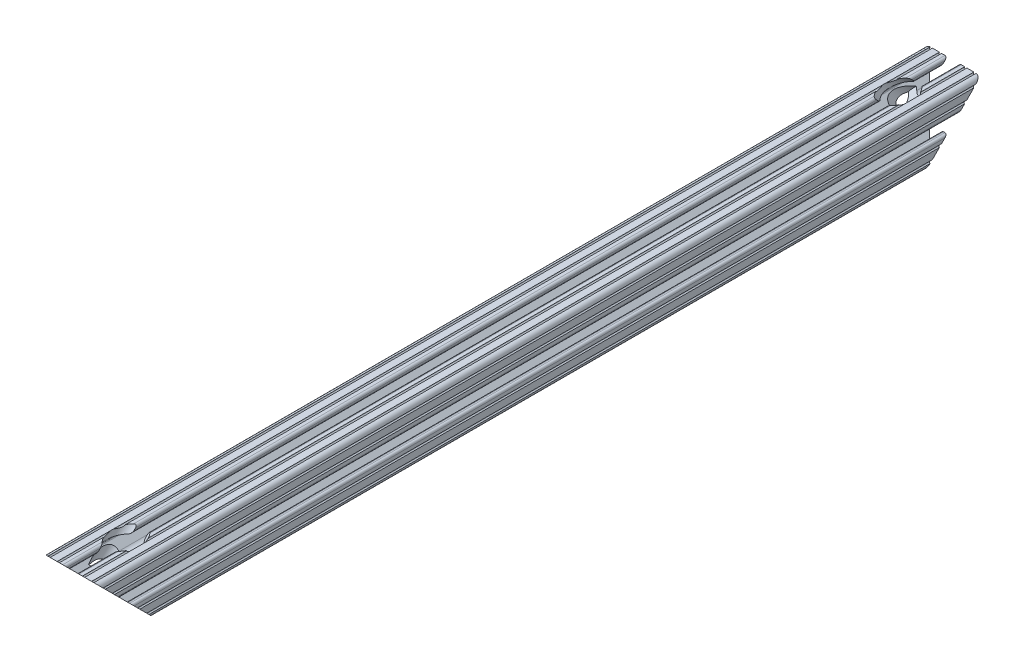
from build123d import *

# Parameters (mm, degrees)
SKETCH1_R               = 3.3274
BOSS_EXTRUDE1_DEPTH     = 304.8
CUT_EXTRUDE1_DEPTH      = 306.988323561
CUT_EXTRUDE1_DEPTH_BACK = 306.988323561


with BuildPart() as part:
    # Sketch1 → Boss-Extrude1 (new, symmetric)
    with BuildSketch(Plane.XY):
        with BuildLine():
            Line((-10.287, 13.552357131), (-10.287, 14.0843))
            ThreePointArc((-10.287, 14.0843), (-10.022898185, 14.721898185), (-9.3853, 14.986))
            Line((-9.3853, 14.986), (-5.617617549, 14.986))
            ThreePointArc((-5.617617549, 14.986), (-4.519044045, 15.441044045), (-4.064, 16.539617549))
            Line((-4.064, 16.539617549), (-4.064, 17.496382451))
            ThreePointArc((-4.064, 17.496382451), (-4.519044045, 18.594955955), (-5.617617549, 19.05))
            Line((-5.617617549, 19.05), (-7.974178704, 19.05))
            ThreePointArc((-7.974178704, 19.05), (-8.736178704, 18.288), (-9.498178704, 19.05))
            Line((-9.498178704, 19.05), (-14.327719207, 19.05))
            ThreePointArc((-14.327719207, 19.05), (-15.087603123, 18.231251131), (-15.847487039, 19.05))
            ThreePointArc((-15.847487039, 19.05), (-18.120176289, 18.120192083), (-19.05, 15.847509295))
            ThreePointArc((-19.05, 15.847509295), (-18.231250992, 15.08762539), (-19.05, 14.327741484))
            Line((-19.05, 14.327741484), (-19.05, 9.496091471))
            ThreePointArc((-19.05, 9.496091471), (-18.231250992, 8.736207565), (-19.05, 7.97632366))
            Line((-19.05, 7.97632366), (-19.05, 5.617617549))
            ThreePointArc((-19.05, 5.617617549), (-18.594955955, 4.519044045), (-17.496382451, 4.064))
            Line((-17.496382451, 4.064), (-16.539617549, 4.064))
            ThreePointArc((-16.539617549, 4.064), (-15.441044045, 4.519044045), (-14.986, 5.617617549))
            Line((-14.986, 5.617617549), (-14.986, 9.385342516))
            ThreePointArc((-14.986, 9.385342516), (-14.721898185, 10.022940701), (-14.0843, 10.287042516))
            Line((-14.0843, 10.287042516), (-13.516042086, 10.287042516))
            ThreePointArc((-13.516042086, 10.287042516), (-13.170975923, 10.218404478), (-12.878443117, 10.022939917))
            Line((-12.878443117, 10.022939917), (-8.14758008, 5.292065243))
            ThreePointArc((-8.14758008, 5.292065243), (-7.117955879, 3.751120653), (-6.7564, 1.933453584))
            Line((-6.7564, 1.933453584), (-6.7564, -1.933453584))
            ThreePointArc((-6.7564, -1.933453584), (-7.117955879, -3.751120653), (-8.14758008, -5.292065243))
            Line((-8.14758008, -5.292065243), (-12.878443117, -10.022939917))
            ThreePointArc((-12.878443117, -10.022939917), (-13.170975923, -10.218404478), (-13.516042086, -10.287042516))
            Line((-13.516042086, -10.287042516), (-14.0843, -10.287042516))
            ThreePointArc((-14.0843, -10.287042516), (-14.721898185, -10.022940701), (-14.986, -9.385342516))
            Line((-14.986, -9.385342516), (-14.986, -5.617617549))
            ThreePointArc((-14.986, -5.617617549), (-15.441044045, -4.519044045), (-16.539617549, -4.064))
            Line((-16.539617549, -4.064), (-17.496382451, -4.064))
            ThreePointArc((-17.496382451, -4.064), (-18.594955955, -4.519044045), (-19.05, -5.617617549))
            Line((-19.05, -5.617617549), (-19.05, -7.976318491))
            ThreePointArc((-19.05, -7.976318491), (-18.231250992, -8.736202396), (-19.05, -9.496086302))
            Line((-19.05, -9.496086302), (-19.05, -14.32774291))
            ThreePointArc((-19.05, -14.32774291), (-18.231250992, -15.087626816), (-19.05, -15.847510721))
            ThreePointArc((-19.05, -15.847510721), (-18.120175716, -18.120192644), (-15.847486868, -19.05))
            ThreePointArc((-15.847486868, -19.05), (-15.087602952, -18.231251131), (-14.327719036, -19.05))
            Line((-14.327719036, -19.05), (-9.496062448, -19.05))
            ThreePointArc((-9.496062448, -19.05), (-8.736178532, -18.231251131), (-7.976294616, -19.05))
            Line((-7.976294616, -19.05), (-5.617617549, -19.05))
            ThreePointArc((-5.617617549, -19.05), (-4.519044045, -18.594955955), (-4.064, -17.496382451))
            Line((-4.064, -17.496382451), (-4.064, -16.539617549))
            ThreePointArc((-4.064, -16.539617549), (-4.519044045, -15.441044045), (-5.617617549, -14.986))
            Line((-5.617617549, -14.986), (-9.3853, -14.986))
            ThreePointArc((-9.3853, -14.986), (-10.022898185, -14.721898185), (-10.287, -14.0843))
            Line((-10.287, -14.0843), (-10.287, -13.552357131))
            ThreePointArc((-10.287, -13.552357131), (-10.218362387, -13.207291992), (-10.022898969, -12.91475973))
            Line((-10.022898969, -12.91475973), (-5.252158105, -8.144007132))
            ThreePointArc((-5.252158105, -8.144007132), (-3.715177372, -7.117027388), (-1.902183975, -6.7564))
            Line((-1.902183975, -6.7564), (1.902183975, -6.7564))
            ThreePointArc((1.902183975, -6.7564), (3.715177372, -7.117027388), (5.252158105, -8.144007132))
            Line((5.252158105, -8.144007132), (10.022898969, -12.91475973))
            ThreePointArc((10.022898969, -12.91475973), (10.218362387, -13.207291992), (10.287, -13.552357131))
            Line((10.287, -13.552357131), (10.287, -14.0843))
            ThreePointArc((10.287, -14.0843), (10.022898185, -14.721898185), (9.3853, -14.986))
            Line((9.3853, -14.986), (5.617617549, -14.986))
            ThreePointArc((5.617617549, -14.986), (4.519044045, -15.441044045), (4.064, -16.539617549))
            Line((4.064, -16.539617549), (4.064, -17.496382451))
            ThreePointArc((4.064, -17.496382451), (4.519044045, -18.594955955), (5.617617549, -19.05))
            Line((5.617617549, -19.05), (7.976294616, -19.05))
            ThreePointArc((7.976294616, -19.05), (8.736178532, -18.231251131), (9.496062448, -19.05))
            Line((9.496062448, -19.05), (14.327719036, -19.05))
            ThreePointArc((14.327719036, -19.05), (15.087602952, -18.231251131), (15.847486868, -19.05))
            ThreePointArc((15.847486868, -19.05), (18.120175716, -18.120192644), (19.05, -15.847510721))
            ThreePointArc((19.05, -15.847510721), (18.231250992, -15.087626816), (19.05, -14.32774291))
            Line((19.05, -14.32774291), (19.05, -9.496086302))
            ThreePointArc((19.05, -9.496086302), (18.231250992, -8.736202396), (19.05, -7.976318491))
            Line((19.05, -7.976318491), (19.05, -5.617617549))
            ThreePointArc((19.05, -5.617617549), (18.594955955, -4.519044045), (17.496382451, -4.064))
            Line((17.496382451, -4.064), (16.539617549, -4.064))
            ThreePointArc((16.539617549, -4.064), (15.441044045, -4.519044045), (14.986, -5.617617549))
            Line((14.986, -5.617617549), (14.986, -9.385342516))
            ThreePointArc((14.986, -9.385342516), (14.721898185, -10.022940701), (14.0843, -10.287042516))
            Line((14.0843, -10.287042516), (13.516042086, -10.287042516))
            ThreePointArc((13.516042086, -10.287042516), (13.170975923, -10.218404478), (12.878443117, -10.022939917))
            Line((12.878443117, -10.022939917), (8.14758008, -5.292065243))
            ThreePointArc((8.14758008, -5.292065243), (7.117955879, -3.751120653), (6.7564, -1.933453584))
            Line((6.7564, -1.933453584), (6.7564, 1.933453584))
            ThreePointArc((6.7564, 1.933453584), (7.117955879, 3.751120653), (8.14758008, 5.292065243))
            Line((8.14758008, 5.292065243), (12.878443117, 10.022939917))
            ThreePointArc((12.878443117, 10.022939917), (13.170975923, 10.218404478), (13.516042086, 10.287042516))
            Line((13.516042086, 10.287042516), (14.0843, 10.287042516))
            ThreePointArc((14.0843, 10.287042516), (14.721898185, 10.022940701), (14.986, 9.385342516))
            Line((14.986, 9.385342516), (14.986, 5.617617549))
            ThreePointArc((14.986, 5.617617549), (15.441044045, 4.519044045), (16.539617549, 4.064))
            Line((16.539617549, 4.064), (17.496382451, 4.064))
            ThreePointArc((17.496382451, 4.064), (18.594955955, 4.519044045), (19.05, 5.617617549))
            Line((19.05, 5.617617549), (19.05, 7.97632366))
            ThreePointArc((19.05, 7.97632366), (18.231250992, 8.736207565), (19.05, 9.496091471))
            Line((19.05, 9.496091471), (19.05, 14.327741484))
            ThreePointArc((19.05, 14.327741484), (18.231250992, 15.08762539), (19.05, 15.847509295))
            ThreePointArc((19.05, 15.847509295), (18.120176289, 18.120192083), (15.847487039, 19.05))
            ThreePointArc((15.847487039, 19.05), (15.087603123, 18.231251131), (14.327719207, 19.05))
            Line((14.327719207, 19.05), (9.498178704, 19.05))
            ThreePointArc((9.498178704, 19.05), (8.736178704, 18.288), (7.974178704, 19.05))
            Line((7.974178704, 19.05), (5.617617549, 19.05))
            ThreePointArc((5.617617549, 19.05), (4.519044045, 18.594955955), (4.064, 17.496382451))
            Line((4.064, 17.496382451), (4.064, 16.539617549))
            ThreePointArc((4.064, 16.539617549), (4.519044045, 15.441044045), (5.617617549, 14.986))
            Line((5.617617549, 14.986), (9.3853, 14.986))
            ThreePointArc((9.3853, 14.986), (10.022898185, 14.721898185), (10.287, 14.0843))
            Line((10.287, 14.0843), (10.287, 13.552357131))
            ThreePointArc((10.287, 13.552357131), (10.218362387, 13.207291992), (10.022898969, 12.91475973))
            Line((10.022898969, 12.91475973), (5.252158105, 8.144007132))
            ThreePointArc((5.252158105, 8.144007132), (3.715177372, 7.117027388), (1.902183975, 6.7564))
            Line((1.902183975, 6.7564), (-1.902183975, 6.7564))
            ThreePointArc((-1.902183975, 6.7564), (-3.715177372, 7.117027388), (-5.252158105, 8.144007132))
            Line((-5.252158105, 8.144007132), (-10.022898969, 12.91475973))
            ThreePointArc((-10.022898969, 12.91475973), (-10.218362387, 13.207291992), (-10.287, 13.552357131))
        make_face()
        with Locations(Location((0, 0, 0), (0, 0, 180))):
            Circle(SKETCH1_R, mode=Mode.SUBTRACT)
    extrude(amount=BOSS_EXTRUDE1_DEPTH, both=True)

    # Sketch2 → Cut-Extrude1 (cut, two sides: drawn at the far end of the back side and taken through both)
    with BuildSketch(Plane(origin=(0, 0, 0), x_dir=(0, 0, -1), z_dir=(1, 0, 0)).offset(-CUT_EXTRUDE1_DEPTH_BACK)):
        Polygon((-304.8, 19.05), (-304.8, -25.4), (-260.35, -25.4), align=None)
        Polygon((260.35, -25.4), (304.8, 19.05), (304.8, -25.4), align=None)
    extrude(amount=CUT_EXTRUDE1_DEPTH + CUT_EXTRUDE1_DEPTH_BACK, mode=Mode.SUBTRACT)

    # Sketch3 → Cut-Revolve1 (revolve, cut)
    with BuildSketch(Plane(origin=(0, 0, 0), x_dir=(0, 0, -1), z_dir=(1, 0, 0))):
        Polygon((-259.964807909, 25.785192091), (-285.75, 0), (-288.057925823, 2.307925823), (-283.567797763, 6.798053884), (-287.99506403, 11.225320151), (-266.7, 32.520384182), align=None)
    cut_revolve1 = revolve(axis=Axis((0, 0, 285.75), (0, -0.7071067811865499, 0.7071067811865451)), mode=Mode.SUBTRACT)

    # Mirror1: Cut-Revolve1 across plane
    add(cut_revolve1.mirror(Plane.XY), mode=Mode.SUBTRACT)


solid = part.part
